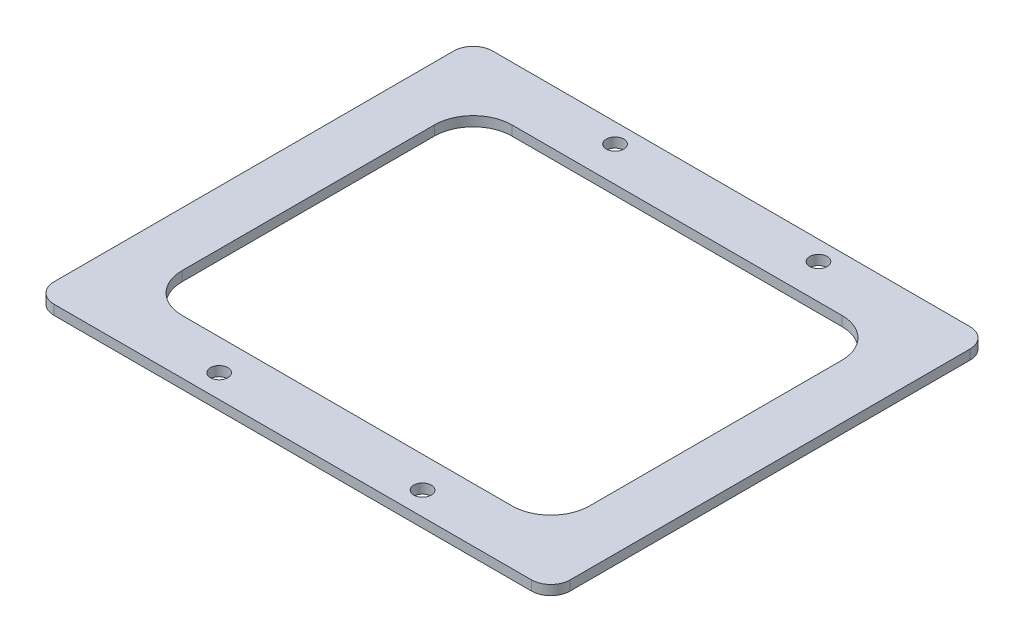
from build123d import *

# Parameters (mm, degrees)
SKETCH1_W            = 168.91
SKETCH1_H            = 143.51
SKETCH1_W_2          = 133.35
SKETCH1_H_2          = 107.95
BOSS_EXTRUDE1_DEPTH  = 3.175
FILLET1_R            = 6.35
FILLET2_R            = 12.7
SKETCH2_R            = 2.8575
CUT_EXTRUDE1_DEPTH   = 4.175
LPATTERN1_COUNT      = 2
LPATTERN1_PITCH      = 66.548
LPATTERN1_COUNT_DIR2 = 2
LPATTERN1_PITCH_DIR2 = 129.54


with BuildPart() as part:
    # Sketch1 → Boss-Extrude1 (new body)
    with BuildSketch(Plane(origin=(0, 0, 0), x_dir=(1, 0, 0), z_dir=(0, 1, 0))):
        Rectangle(SKETCH1_W, SKETCH1_H)
        Rectangle(SKETCH1_W_2, SKETCH1_H_2, mode=Mode.SUBTRACT)
    extrude(amount=BOSS_EXTRUDE1_DEPTH)

    # Fillet1
    fillet1_edges = [part.edges().sort_by_distance(p)[0] for p in [
        (-84.455, 1.5875, 71.755),
        (-84.455, 1.5875, -71.755),
        (84.455, 1.5875, -71.755),
        (84.455, 1.5875, 71.755),
    ]]
    fillet(fillet1_edges, radius=FILLET1_R)

    # Fillet2
    fillet2_edges = [part.edges().sort_by_distance(p)[0] for p in [
        (-66.675, 1.5875, -53.975),
        (-66.675, 1.5875, 53.975),
        (66.675, 1.5875, 53.975),
        (66.675, 1.5875, -53.975),
    ]]
    fillet(fillet2_edges, radius=FILLET2_R)

    # Sketch2 → Cut-Extrude1 (cut, through all)
    with BuildSketch(Plane(origin=(0, 3.175, 0), x_dir=(1, 0, 0), z_dir=(0, 1, 0))):
        with Locations((-31.6865, 65.405)):
            Circle(SKETCH2_R)
    cut_extrude1 = extrude(amount=-CUT_EXTRUDE1_DEPTH, mode=Mode.SUBTRACT)

    # LPattern1: Cut-Extrude1 2 × 2
    with Locations(*[(i * LPATTERN1_PITCH, 0, j * LPATTERN1_PITCH_DIR2) for i in range(LPATTERN1_COUNT) for j in range(LPATTERN1_COUNT_DIR2) if (i, j) != (0, 0)]):
        add(cut_extrude1, mode=Mode.SUBTRACT)


solid = part.part
